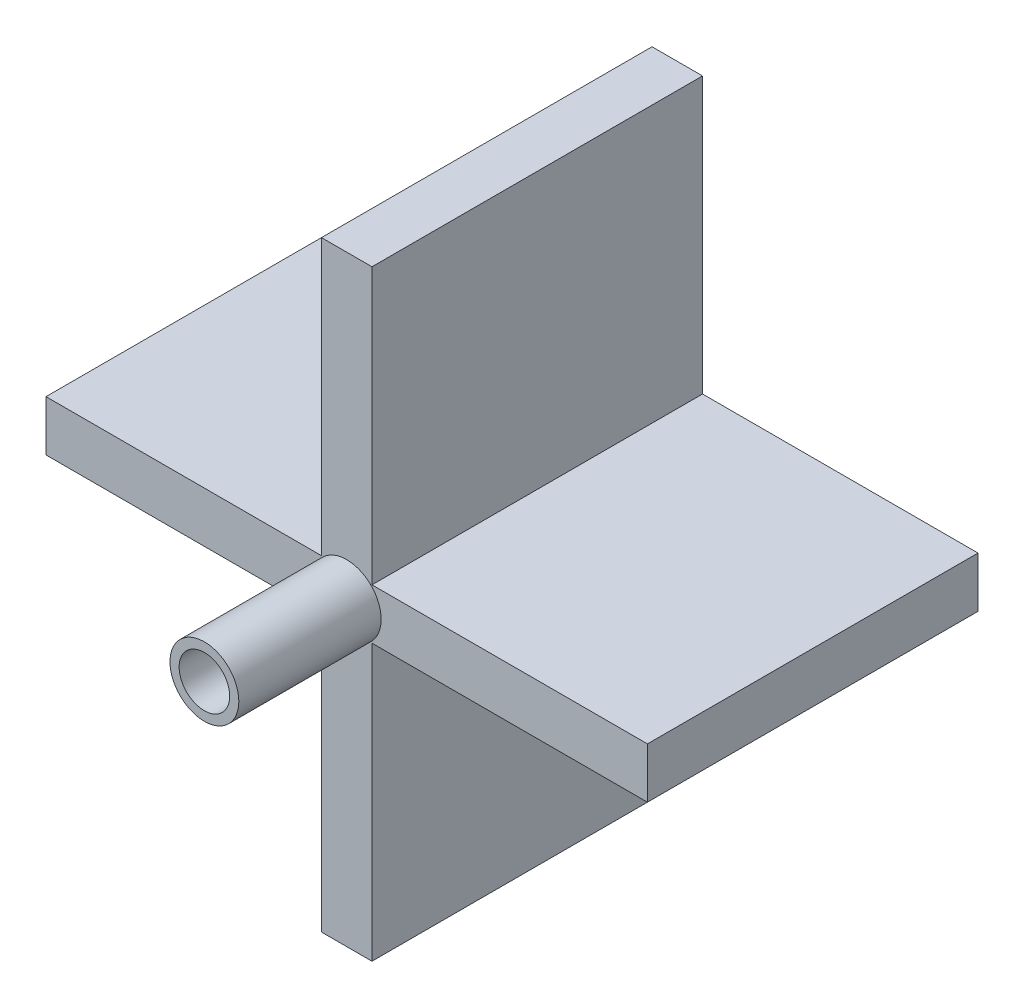
from build123d import *

# Parameters (mm, degrees)
SKETCH_1_W          = 5.5
SKETCH_1_H          = 30
SKETCH_1_W_2        = 30
SKETCH_1_H_2        = 5.5
EXTRUDE_1_DEPTH     = 36
SKETCH_5_R          = 3.75
EXTRUDE_3_DEPTH     = 15.5
SKETCH_6_R          = 2.85
CUT_EXTRUDE_1_DEPTH = 5
SKETCH_7_R          = 1.75
CUT_EXTRUDE_2_DEPTH = 52.5
SKETCH_8_R          = 2.75
CUT_EXTRUDE_3_DEPTH = 10


with BuildPart() as part:
    # 草圖1 → 填料-伸長1 (new body)
    with BuildSketch(Plane.XY):
        with Locations((-13.901604276, 23.24099723)):
            Rectangle(SKETCH_1_W, SKETCH_1_H)
        with Locations((-31.651604276, 5.49099723)):
            Rectangle(SKETCH_1_W_2, SKETCH_1_H_2)
        with Locations((-13.901604276, -12.25900277)):
            Rectangle(SKETCH_1_W, SKETCH_1_H)
        with Locations((3.848395724, 5.49099723)):
            Rectangle(SKETCH_1_W_2, SKETCH_1_H_2)
        with Locations((-13.901604276, 5.49099723)):
            Rectangle(SKETCH_1_W, SKETCH_1_H_2)
    extrude(amount=EXTRUDE_1_DEPTH)

    # 草圖5 → 填料-伸長3 (add)
    with BuildSketch(Plane.XY.offset(36)):
        with Locations((-13.901604276, 5.49099723)):
            Circle(SKETCH_5_R)
    extrude(amount=EXTRUDE_3_DEPTH)

    # 草圖6 → 除料-伸長1 (cut)
    with BuildSketch(Plane(origin=(0, 0, 0), x_dir=(-1, 0, 0), z_dir=(0, 0, -1))):
        with Locations((13.901604276, 5.49099723)):
            Circle(SKETCH_6_R)
    extrude(amount=-CUT_EXTRUDE_1_DEPTH, mode=Mode.SUBTRACT)

    # 草圖7 → 除料-伸長2 (cut, through all)
    with BuildSketch(Plane.XY.offset(51.5)):
        with Locations((-13.901604276, 5.49099723)):
            Circle(SKETCH_7_R)
    extrude(amount=-CUT_EXTRUDE_2_DEPTH, mode=Mode.SUBTRACT)

    # 草圖8 → 除料-伸長3 (cut)
    with BuildSketch(Plane.XY.offset(51.5)):
        with Locations((-13.901604276, 5.49099723)):
            Circle(SKETCH_8_R)
    extrude(amount=-CUT_EXTRUDE_3_DEPTH, mode=Mode.SUBTRACT)


solid = part.part
